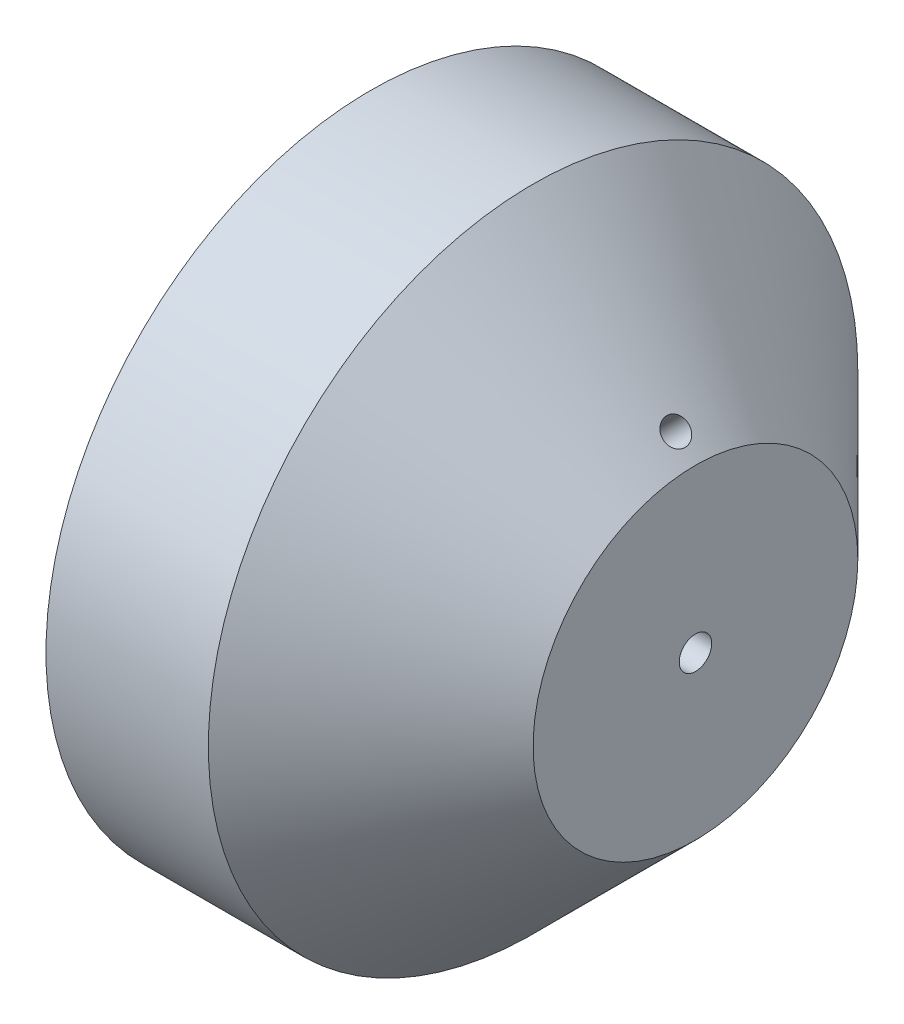
from build123d import *

# Parameters (mm, degrees)
SKIZZE1_R                           = 50
SKIZZE1_R_2                         = 2.5
AUFSATZ_LINEAR_AUSTRAGEN1_DEPTH     = 50
FASE1_SIZE                          = 25
F_4_0_4_DURCHMESSER_BOHRUNG1_REACH  = 90.388
F_4_0_4_DURCHMESSER_BOHRUNG1_BORE_R = 2


with BuildPart() as part:
    # Skizze1 → Aufsatz-Linear austragen1 (new body)
    with BuildSketch(Plane(origin=(0, 0, 0), x_dir=(0, 0, -1), z_dir=(1, 0, 0))):
        Circle(SKIZZE1_R)
        Circle(SKIZZE1_R_2, mode=Mode.SUBTRACT)
    extrude(amount=AUFSATZ_LINEAR_AUSTRAGEN1_DEPTH)

    # Fase1
    fase1_edges = [part.edges().sort_by_distance(p)[0] for p in [
        (50, 0, 50),
    ]]
    chamfer(fase1_edges, length=FASE1_SIZE)

    # Ø4.0 (4) Durchmesser Bohrung1 bore (on position points) → Ø4.0 (4) Durchmesser Bohrung1 (cut, up to next)
    with BuildSketch(Plane(origin=(47, 28, 0), x_dir=(0.707106781, -0.707106781, 0), z_dir=(0.707106781, 0.707106781, 0)), mode=Mode.PRIVATE) as f_4_0_4_durchmesser_bohrung1_sk1:
        Circle(F_4_0_4_DURCHMESSER_BOHRUNG1_BORE_R)
    f_4_0_4_durchmesser_bohrung1_tool1 = extrude(f_4_0_4_durchmesser_bohrung1_sk1.sketch, amount=-F_4_0_4_DURCHMESSER_BOHRUNG1_REACH, mode=Mode.PRIVATE) & part.part
    add(f_4_0_4_durchmesser_bohrung1_tool1.solids().sort_by_distance((47, 28, 0))[0], mode=Mode.SUBTRACT)


solid = part.part
